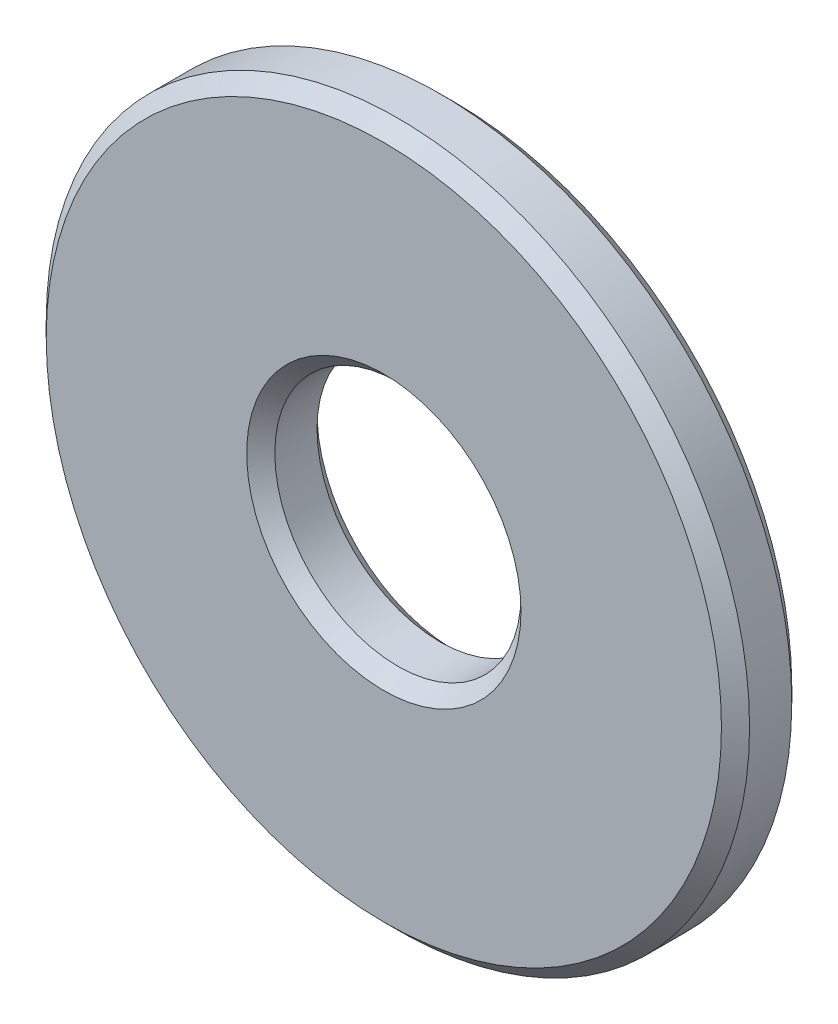
from build123d import *

# Parameters (mm, degrees)
SKETCH1_R           = 5
SKETCH1_R_2         = 1.75
BOSS_EXTRUDE1_DEPTH = 1
CHAMFER1_SIZE       = 0.2


with BuildPart() as part:
    # Sketch1 → Boss-Extrude1 (new body)
    with BuildSketch(Plane.XY):
        Circle(SKETCH1_R)
        Circle(SKETCH1_R_2, mode=Mode.SUBTRACT)
    extrude(amount=BOSS_EXTRUDE1_DEPTH)

    # Chamfer1
    chamfer1_edges = [part.edges().sort_by_distance(p)[0] for p in [
        (-5, 0, 0),
        (-5, 0, 1),
        (-1.75, 0, 0),
        (-1.75, 0, 1),
    ]]
    chamfer(chamfer1_edges, length=CHAMFER1_SIZE)


solid = part.part
